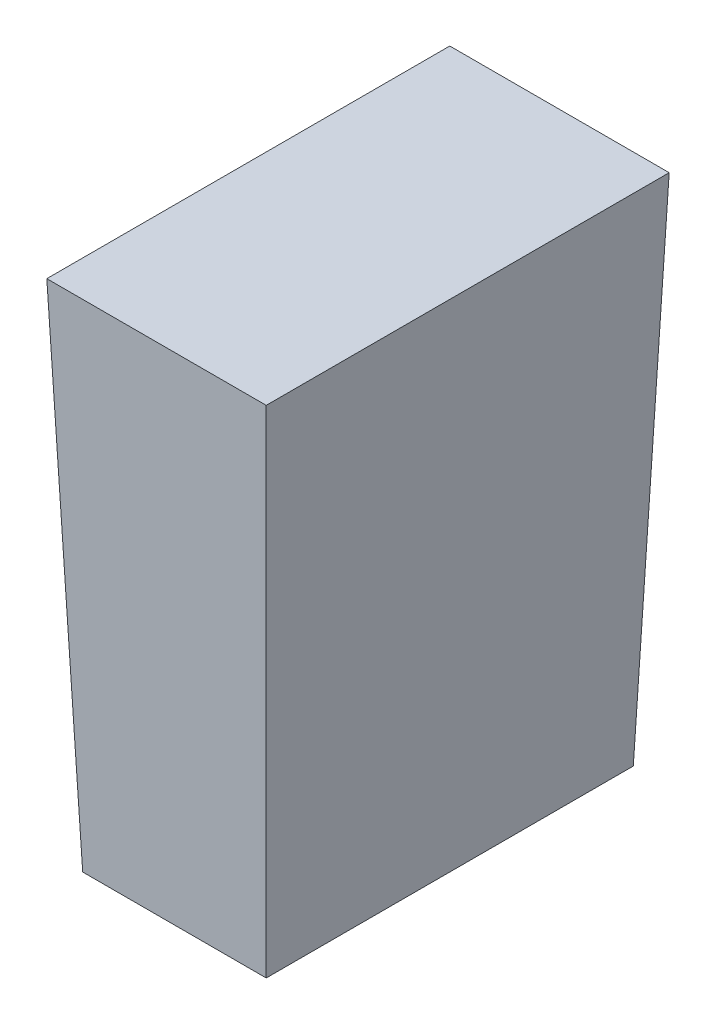
from build123d import *

# Parameters (mm, degrees)
SKETCH1_W           = 3.175
SKETCH1_H           = 6.35
BOSS_EXTRUDE1_DEPTH = 8.89
BOSS_EXTRUDE1_TAPER = -2


with BuildPart() as part:
    # Sketch1 → Boss-Extrude1 (new body)
    with BuildSketch(Plane(origin=(0, 0, 0), x_dir=(1, 0, 0), z_dir=(0, 1, 0))):
        Rectangle(SKETCH1_W, SKETCH1_H)
    extrude(amount=BOSS_EXTRUDE1_DEPTH, taper=BOSS_EXTRUDE1_TAPER)


solid = part.part
